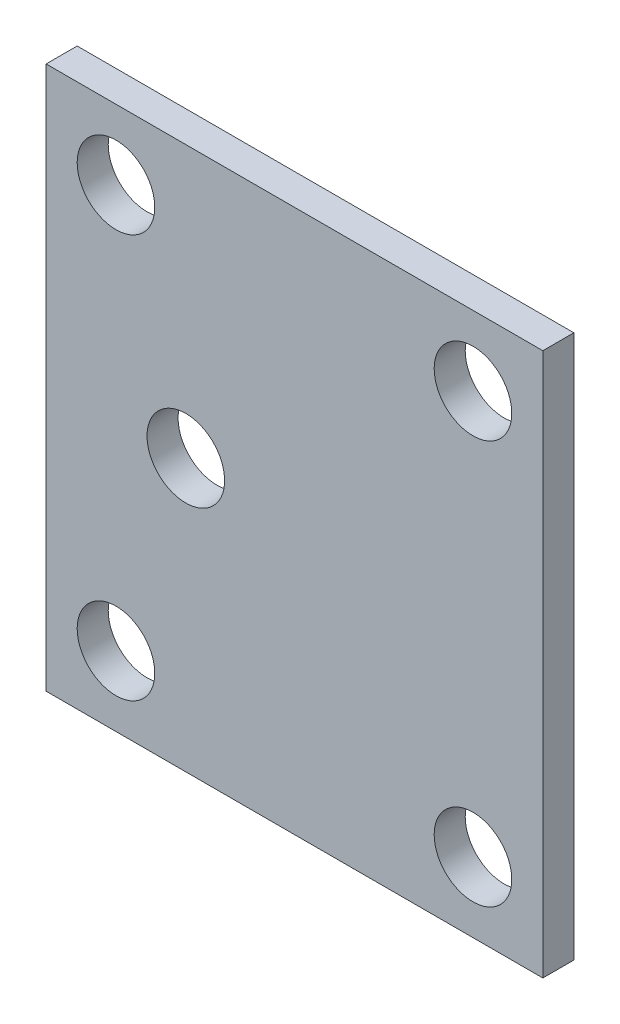
from build123d import *

# Parameters (mm, degrees)
SKETCH1_W           = 32
SKETCH1_H           = 35
BOSS_EXTRUDE1_DEPTH = 2
M6_TAPPED_HOLE3_D   = 5
M6_TAPPED_HOLE4_D   = 5


with BuildPart() as part:
    # Sketch1 → Boss-Extrude1 (new body)
    with BuildSketch(Plane.XY):
        with Locations((1.67, -5.25)):
            Rectangle(SKETCH1_W, SKETCH1_H)
    extrude(amount=BOSS_EXTRUDE1_DEPTH)

    # M6 Tapped Hole3 (through all)
    with Locations(Plane(origin=(0, 0, 0), x_dir=(-1, 0, 0), z_dir=(0, 0, -1))):
        with Locations((9.83, -18.25), (-13.17, -18.25), (-13.17, 7.75), (9.83, 7.75)):
            Hole(M6_TAPPED_HOLE3_D / 2)

    # M6 Tapped Hole4 (through all)
    with Locations(Plane(origin=(0, 0, 0), x_dir=(-1, 0, 0), z_dir=(0, 0, -1))):
        with Locations((5.33, -5.25)):
            Hole(M6_TAPPED_HOLE4_D / 2)


solid = part.part
